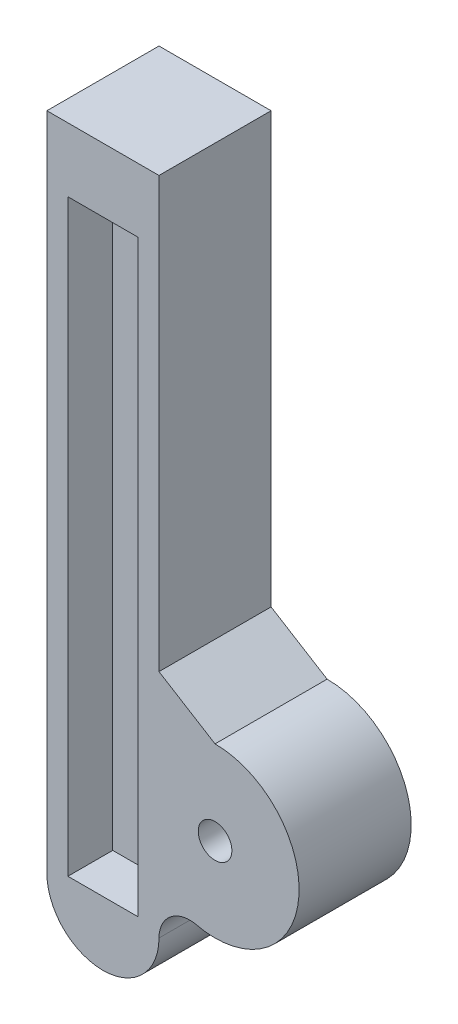
from build123d import *

# Parameters (mm, degrees)
SKETCH1_R             = 3
BOSS_EXTRUDE1_DEPTH   = 20
SKETCH8_W             = 105
SKETCH8_H             = 12.5
CUT_EXTRUDE7_DEPTH    = 8
SKETCH9_W             = 105
SKETCH9_H             = 12.5
CUT_EXTRUDE8_DEPTH    = 8
BODY_MOVE_COPY1_ANGLE = 90
BODY_MOVE_COPY2_ANGLE = 180
BODY_MOVE_COPY6_ANGLE = 90


with BuildPart() as part:
    # Sketch1 → Boss-Extrude1 (new body)
    with BuildSketch(Plane(origin=(0, 0, 0), x_dir=(1, 0, 0), z_dir=(0, 1, 0))):
        with BuildLine():
            Line((-20, 30), (97.83, 30))
            Line((97.83, 30), (97.83, 10))
            Line((97.83, 10), (21.160500507, 10))
            Line((21.160500507, 10), (15, 0))
            ThreePointArc((15, 0), (-1.903014387, -14.878794852), (-14.517138166, 3.775274755))
            ThreePointArc((-14.517138166, 3.775274755), (-15.852441132, 8.126182851), (-20, 10))
            ThreePointArc((-20, 10), (-30, 20), (-20, 30))
        make_face()
        Circle(SKETCH1_R, mode=Mode.SUBTRACT)
    extrude(amount=BOSS_EXTRUDE1_DEPTH)

    # Sketch8 → Cut-Extrude7 (cut)
    with BuildSketch(Plane.XZ):
        with Locations((33.915, -20.25)):
            Rectangle(SKETCH8_W, SKETCH8_H)
    extrude(amount=-CUT_EXTRUDE7_DEPTH, mode=Mode.SUBTRACT)

    # Sketch9 → Cut-Extrude8 (cut)
    with BuildSketch(Plane(origin=(0, 20, 0), x_dir=(1, 0, 0), z_dir=(0, 1, 0))):
        with Locations((33.915, 20)):
            Rectangle(SKETCH9_W, SKETCH9_H)
    extrude(amount=-CUT_EXTRUDE8_DEPTH, mode=Mode.SUBTRACT)


with BuildPart() as part_1:
    # Body-Move/Copy1: moved
    add(part.part.rotate(Axis((0, 10, -7.5), (-1, 0, 0)), BODY_MOVE_COPY1_ANGLE))


with BuildPart() as part_2:
    # Body-Move/Copy2: moved
    add(part_1.part.rotate(Axis((0, 10, -7.5), (1, 0, 0)), BODY_MOVE_COPY2_ANGLE))


with BuildPart() as part_3:
    # Body-Move/Copy5: moved
    add(part_2.part.moved(Location((0, -2.5, -2.5))))


with BuildPart() as part_4:
    # Body-Move/Copy6: moved
    add(part_3.part.rotate(Axis((33.915, 7.5, 0), (0, 0, 1)), BODY_MOVE_COPY6_ANGLE))


with BuildPart() as part_5:
    # Body-Move/Copy7: moved
    add(part_4.part.moved(Location((-41.415, 26.415, 0))))


solid = part_5.part
